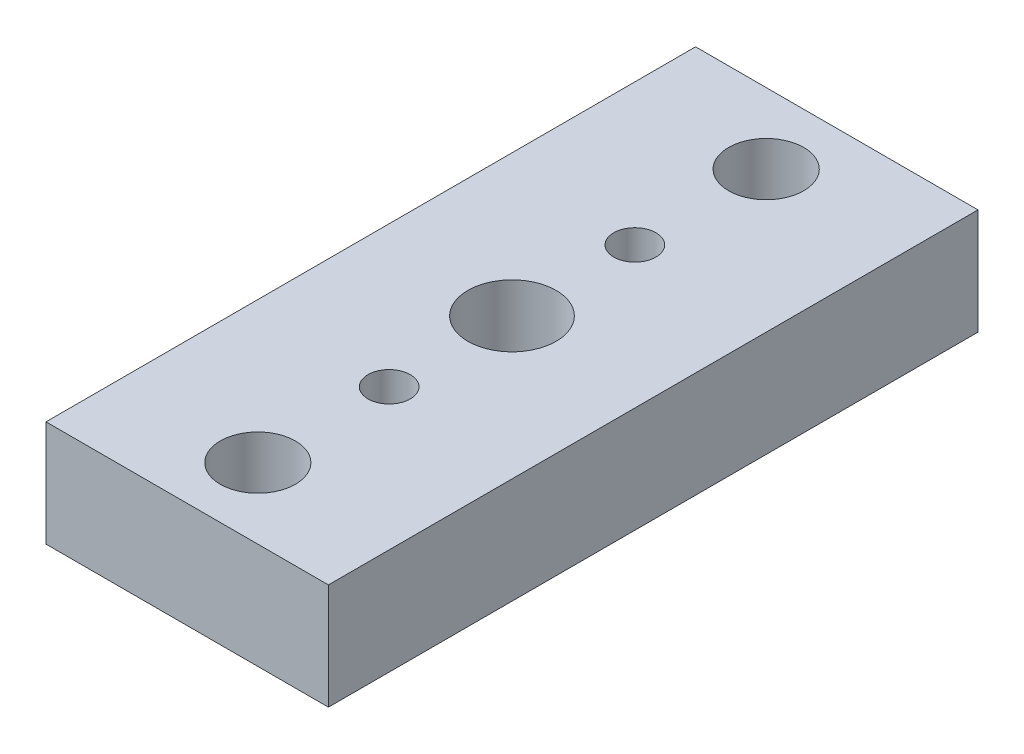
from build123d import *

# Parameters (mm, degrees)
SKETCH1_W                   = 25.4
SKETCH1_H                   = 9.525
EXTRUDE1_DEPTH              = 58.42
F_1_4_CLEARANCE_HOLE1_D     = 6.7564
F_1_4_CLEARANCE_HOLE1_DEPTH = 12.7
F_1_4_CLEARANCE_HOLE1_TIP   = 2.029827343
F_3_8_16_TAPPED_HOLE1_D     = 7.9375
F_10_24_TAPPED_HOLE1_D      = 3.7973
CIRPATTERN1_COUNT           = 2


with BuildPart() as part:
    # Sketch1 → Extrude1 (new body)
    with BuildSketch(Plane.XY):
        Rectangle(SKETCH1_W, SKETCH1_H)
    extrude(amount=EXTRUDE1_DEPTH)

    # 1/4 Clearance Hole1
    with Locations(Plane(origin=(0, 4.7625, 6.35), x_dir=(0, 0, 1), z_dir=(0, 1, 0))):
        with Locations((0, 0), (45.72, 0)):
            Hole(F_1_4_CLEARANCE_HOLE1_D / 2, depth=F_1_4_CLEARANCE_HOLE1_DEPTH)
            with Locations((0, 0, -(F_1_4_CLEARANCE_HOLE1_DEPTH + F_1_4_CLEARANCE_HOLE1_TIP / 2))):  # 118° drill point
                Cone(0, F_1_4_CLEARANCE_HOLE1_D / 2, F_1_4_CLEARANCE_HOLE1_TIP, mode=Mode.SUBTRACT)

    # 3/8-16 Tapped Hole1 (through all)
    with Locations(Plane(origin=(0, 4.7625, 29.21), x_dir=(0, 0, 1), z_dir=(0, 1, 0))):
        with Locations((0, 0)):
            Hole(F_3_8_16_TAPPED_HOLE1_D / 2)

    # #10-24 Tapped Hole1 (through all)
    with Locations(Plane(origin=(0, 4.7625, 40.259), x_dir=(0, 0, 1), z_dir=(0, 1, 0))):
        with Locations((0, 0)):
            f_10_24_tapped_hole1 = Hole(F_10_24_TAPPED_HOLE1_D / 2)

    # CirPattern1: #10-24 Tapped Hole1 ×2 about axis
    cirpattern1_axis = Axis((0, 0, 29.21), (0, 1, 0))
    for i in range(1, CIRPATTERN1_COUNT):
        add(f_10_24_tapped_hole1.rotate(cirpattern1_axis, i * 360 / CIRPATTERN1_COUNT), mode=Mode.SUBTRACT)


solid = part.part
